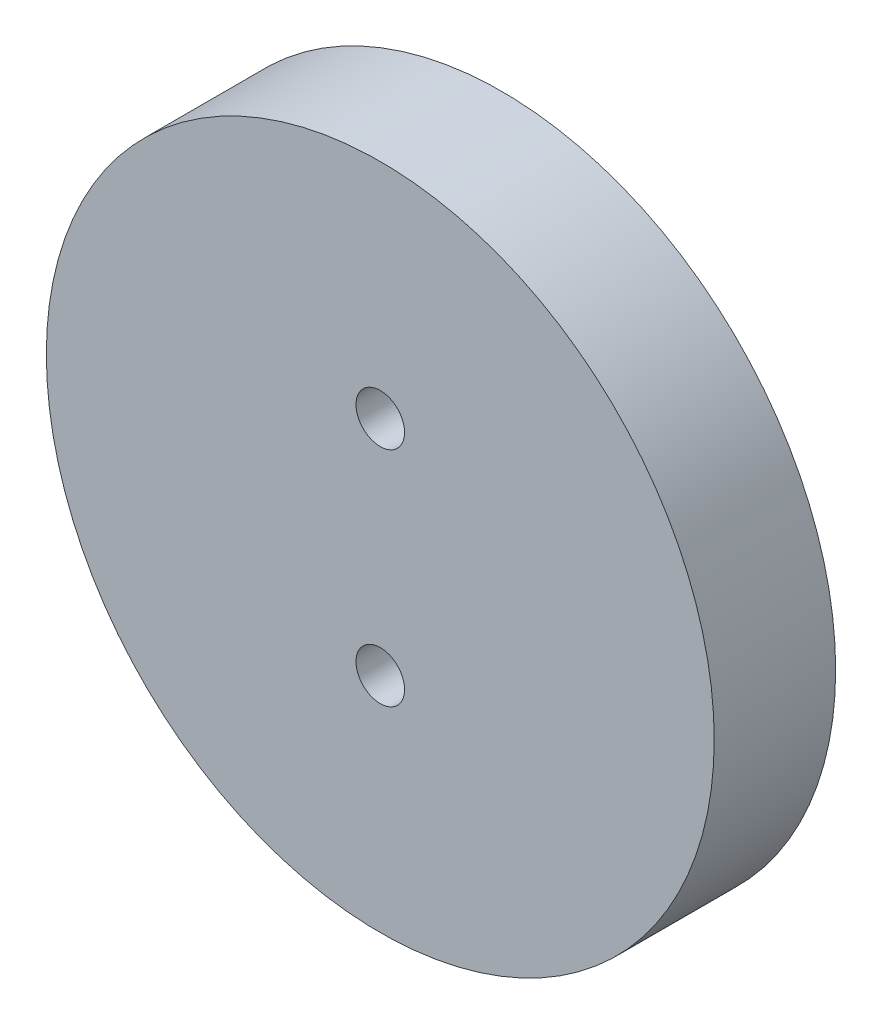
from build123d import *

# Parameters (mm, degrees)
SKETCH1_R                                           = 34.925
BOSS_EXTRUDE1_DEPTH                                 = 12.7
CBORE_FOR_10_BINDING_HEAD_MACHINE_SCREW_D           = 5.08
CBORE_FOR_10_BINDING_HEAD_MACHINE_SCREW_CBORE_D     = 11.1125
CBORE_FOR_10_BINDING_HEAD_MACHINE_SCREW_CBORE_DEPTH = 6.35


with BuildPart() as part:
    # Sketch1 → Boss-Extrude1 (new body)
    with BuildSketch(Plane.XY):
        Circle(SKETCH1_R)
    extrude(amount=BOSS_EXTRUDE1_DEPTH)

    # CBORE for #10 Binding Head Machine Screw1 (through all)
    with Locations(Plane(origin=(0, 0, 0), x_dir=(1, 0, 0), z_dir=(0, 0, -1))):
        with Locations((0, -11.641666667), (0, 11.641666667)):
            CounterBoreHole(CBORE_FOR_10_BINDING_HEAD_MACHINE_SCREW_D / 2, CBORE_FOR_10_BINDING_HEAD_MACHINE_SCREW_CBORE_D / 2, CBORE_FOR_10_BINDING_HEAD_MACHINE_SCREW_CBORE_DEPTH)


solid = part.part
